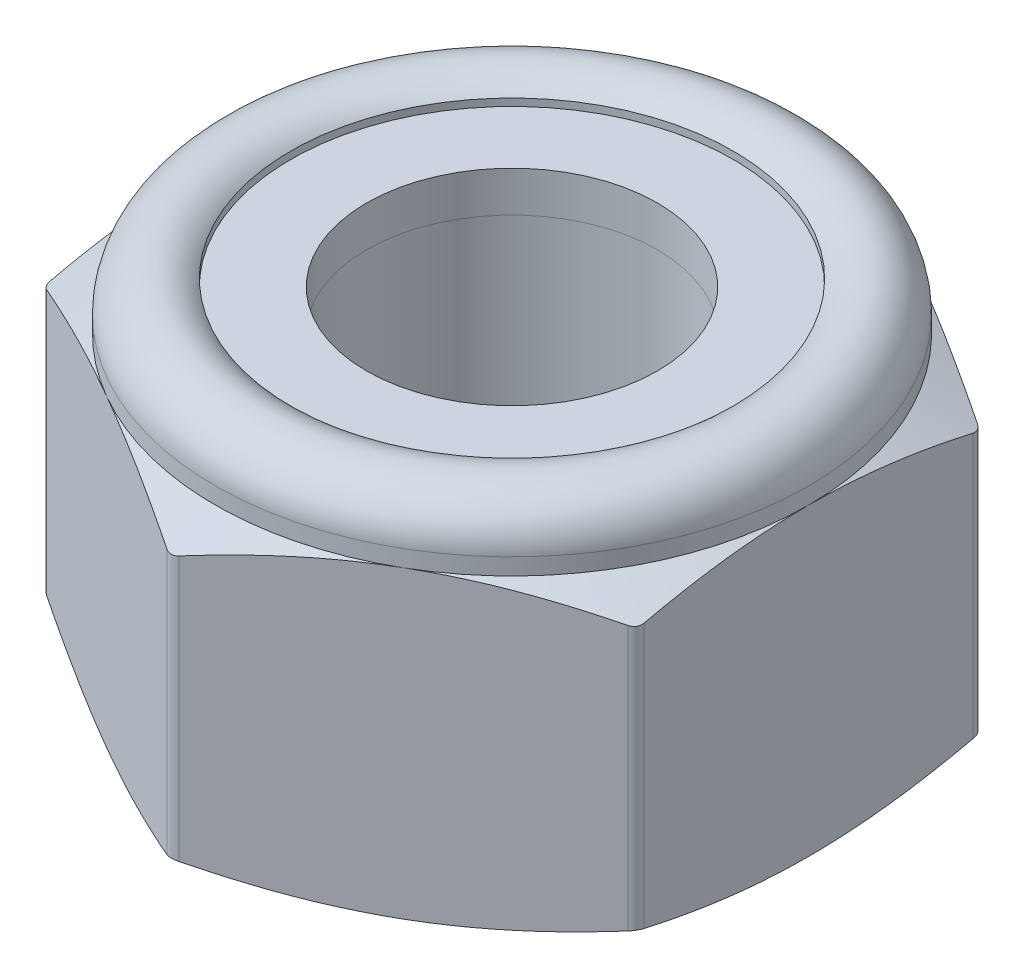
from build123d import *

# Parameters (mm, degrees)
SKETCH2_R                = 3.188101184
BOSS_EXTRUDE1_DEPTH      = 4
BOSS_EXTRUDE1_DEPTH_BACK = 4
FILLET1_R                = 0.26
SKETCH4_W                = 1.655949408
SKETCH4_H                = 0.889217332


with BuildPart() as part:
    # Sketch2 → Boss-Extrude1 (new body, two sides)
    with BuildSketch(Plane(origin=(0, 0, 0), x_dir=(1, 0, 0), z_dir=(0, 1, 0))) as boss_extrude1_sk:
        Polygon((0, 7.505553499), (-6.5, 3.75277675), (-6.5, -3.75277675), (0, -7.505553499), (6.5, -3.75277675), (6.5, 3.75277675), align=None)
        Circle(SKETCH2_R, mode=Mode.SUBTRACT)
    extrude(amount=BOSS_EXTRUDE1_DEPTH)
    extrude(boss_extrude1_sk.sketch, amount=-BOSS_EXTRUDE1_DEPTH_BACK)

    # Fillet1
    fillet1_edges = [part.edges().sort_by_distance(p)[0] for p in [
        (6.5, 0, -3.75277675),
        (6.5, 0, 3.75277675),
        (0, 0, 7.505553499),
        (-6.5, 0, 3.75277675),
        (-6.5, 0, -3.75277675),
        (0, 0, -7.505553499),
    ]]
    fillet(fillet1_edges, radius=FILLET1_R)

    # Sketch3 → Cut-Revolve2 (revolve, cut)
    with BuildSketch(Plane(origin=(0, 0, 0), x_dir=(0, 0, -1), z_dir=(1, 0, 0))):
        with BuildLine():
            Line((7.505553499, 2.666666667), (7.505553499, 5))
            Line((7.505553499, 5), (3.188101184, 5))
            Line((3.188101184, 5), (3.188101184, 2.666666667))
            Line((3.188101184, 2.666666667), (4.844050592, 2.666666667))
            Line((4.844050592, 2.666666667), (4.844050592, 3.715883999))
            ThreePointArc((4.844050592, 3.715883999), (5.90118274, 3.926160657), (6.5, 3.029967295))
            Line((6.5, 3.029967295), (6.5, 2.666666667))
            Line((6.5, 2.666666667), (7.505553499, 2.197769369))
            Line((7.505553499, 2.197769369), (7.505553499, 2.666666667))
        make_face()
        Polygon((6.5, -4), (7.505553499, -3.531102703), (7.505553499, -4), align=None)
        Polygon((3.188101184, -4), (3.188101184, -3.2), (3.988101184, -4), align=None)
    revolve(axis=Axis((0, -4, 0), (0, 1, 0)), mode=Mode.SUBTRACT)


with BuildPart() as body_2:
    # Sketch4 → Revolve1 (revolve)
    with BuildSketch(Plane(origin=(0, 0, 0), x_dir=(0, 0, -1), z_dir=(1, 0, 0))):
        with Locations((-4.016075888, 3.111275333)):
            Rectangle(SKETCH4_W, SKETCH4_H)
    revolve(axis=Axis((0, -4, 0), (0, 1, 0)))


solid = Compound([part.part, body_2.part])
